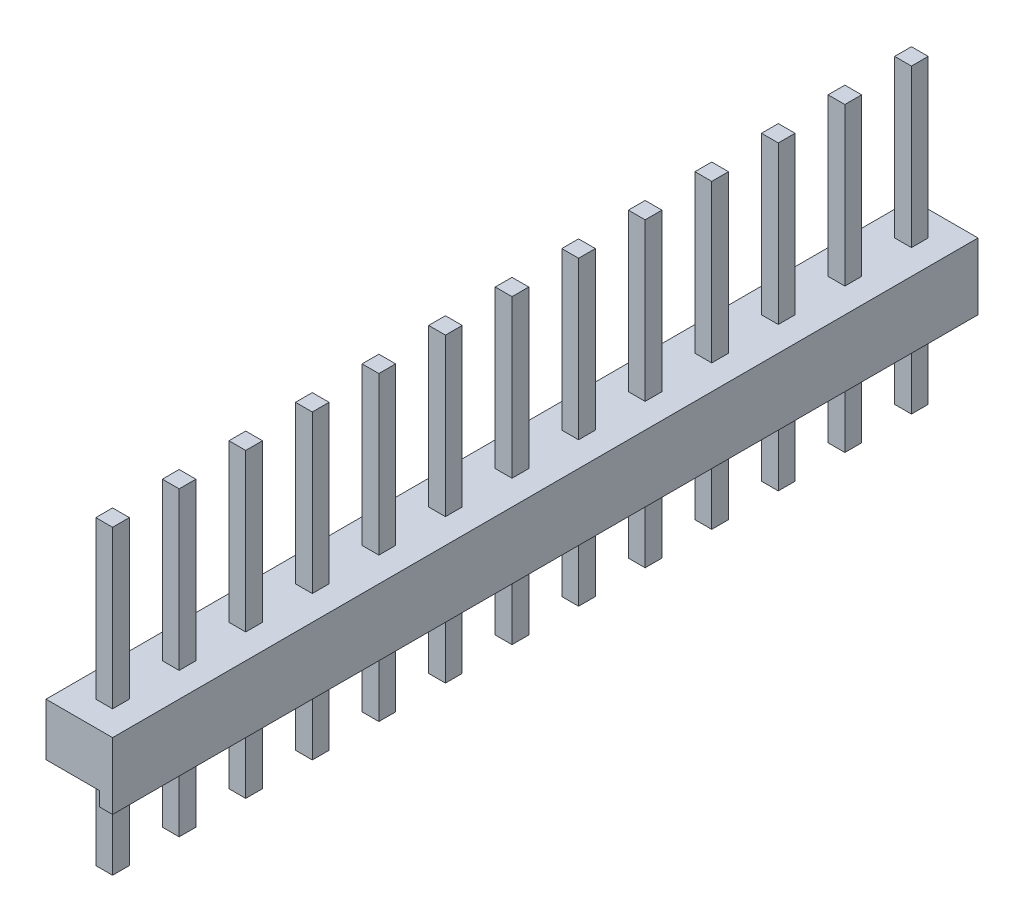
from build123d import *

# Parameters (mm, degrees)
EXTRUDE_1_DEPTH            = 2.54
EXTRUDE_START              = -5.5
SKETCH_2_W                 = 0.64
SKETCH_2_H                 = 0.64
EXTRUDE_2_DEPTH            = 11.5
PATTERN_LINEAR_27_COUNT    = 13
PATTERN_LINEAR_27_PITCH    = 2.54
CROQUIS1_W                 = 6.114803871
CROQUIS1_H                 = 33.02
CORTAR_EXTRUIR1_DEPTH      = 9.54
CORTAR_EXTRUIR1_DEPTH_BACK = 3.96


with BuildPart() as part:
    # Эскиз1 → Бобышка-Вытянуть1 (new body)
    with BuildSketch(Plane.XY):
        Polygon((-2.54, 0), (-2.54, 2.54), (2.54, 2.54), (2.54, 0), (2.04, 0), (2.04, 0.54), (-2.04, 0.54), (-2.04, 0), align=None)
    extrude_1 = extrude(amount=EXTRUDE_1_DEPTH)

    # Эскиз2 → Бобышка-Вытянуть2 (add)
    with BuildSketch(Plane(origin=(0, 2.54, 0), x_dir=(1, 0, 0), z_dir=(0, 1, 0)).offset(EXTRUDE_START)):
        with Locations((-1.27, -1.27)):
            Rectangle(SKETCH_2_W, SKETCH_2_H)
        with Locations((1.27, -1.27)):
            Rectangle(SKETCH_2_W, SKETCH_2_H)
    extrude_2 = extrude(amount=EXTRUDE_2_DEPTH)

    # Линейный массив27: Бобышка-Вытянуть1, Бобышка-Вытянуть2 ×13
    with Locations(*[(0, 0, -i * PATTERN_LINEAR_27_PITCH) for i in range(1, PATTERN_LINEAR_27_COUNT)]):
        add(extrude_1)
        add(extrude_2)

    # Croquis1 → Cortar-Extruir1 (cut, two sides)
    with BuildSketch(Plane(origin=(0, 0, 0), x_dir=(1, 0, 0), z_dir=(0, 1, 0))) as cortar_extruir1_sk:
        with Locations((-3.057401936, 13.97)):
            Rectangle(CROQUIS1_W, CROQUIS1_H)
    extrude(amount=CORTAR_EXTRUIR1_DEPTH, mode=Mode.SUBTRACT)
    extrude(cortar_extruir1_sk.sketch, amount=-CORTAR_EXTRUIR1_DEPTH_BACK, mode=Mode.SUBTRACT)


solid = part.part
